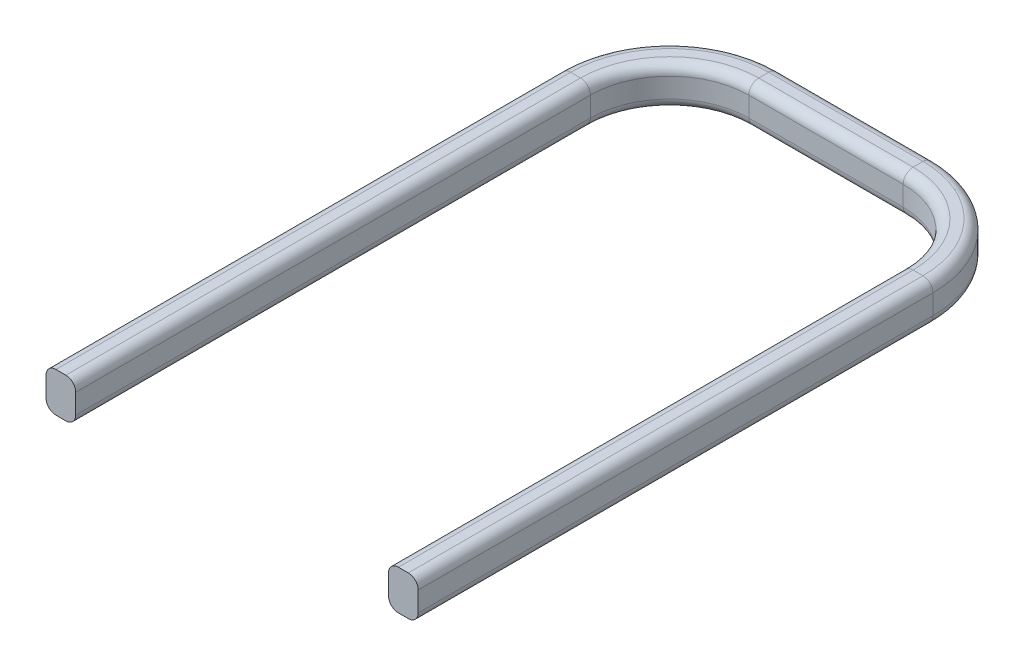
from build123d import *

# Parameters (mm, degrees)
SKETCH2_W    = 0.75
SKETCH2_H    = 1
FILLET1_R    = 0.25
SCALE1_SCALE = 10


with BuildPart() as part:
    # Sweep1: sweep along a path in Sketch1
    with BuildLine(Plane(origin=(0, 0, 0), x_dir=(1, 0, 0), z_dir=(0, 1, 0))) as sweep1_path:
        Line((-3.95, 0), (-3.95, 13))
        ThreePointArc((-3.95, 13), (-3.364213562, 14.414213562), (-1.95, 15))
        Line((-1.95, 15), (1.95, 15))
        ThreePointArc((1.95, 15), (3.364213562, 14.414213562), (3.95, 13))
        Line((3.95, 13), (3.95, 0))
    # Sketch2 → Sweep1 (sweep)
    with BuildSketch(Plane.XY):
        with Locations((-4.325, 0.5)):
            Rectangle(SKETCH2_W, SKETCH2_H)
    sweep(path=sweep1_path.line)

    # Fillet1
    fillet1_edges = [part.edges().sort_by_distance(p)[0] for p in [
        (3.95, 1, -6.5),
        (4.7, 1, -6.5),
        (4.7, 0, -6.5),
        (-3.95, 0, -6.5),
        (-3.95, 1, -6.5),
        (-4.7, 1, -6.5),
        (-4.7, 0, -6.5),
        (-3.364213562, 0, -14.414213562),
        (-3.364213562, 1, -14.414213562),
        (-3.894543648, 1, -14.944543648),
        (-3.894543648, 0, -14.944543648),
        (0, 0, -15),
        (0, 1, -15),
        (0, 1, -15.75),
        (0, 0, -15.75),
        (3.364213562, 0, -14.414213562),
        (3.364213562, 1, -14.414213562),
        (3.894543648, 1, -14.944543648),
        (3.894543648, 0, -14.944543648),
        (3.95, 0, -6.5),
    ]]
    fillet(fillet1_edges, radius=FILLET1_R)


with BuildPart() as part_1:
    # Scale1: scaled about (0, 0.5, -9.028741483)
    add(part.part.scale(SCALE1_SCALE).moved(Location((0, -4.5, 81.258673347))))


solid = part_1.part
